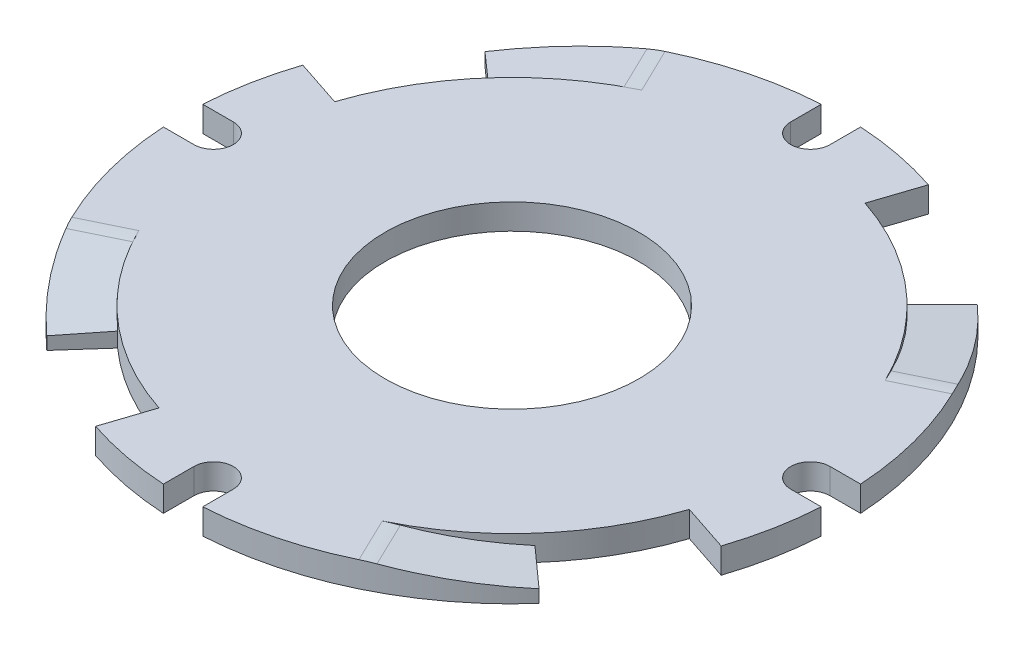
from build123d import *

# Parameters (mm, degrees)
ESQUISSE2_R                  = 10
BOSS_EXTRU_1_DEPTH           = 2
ENL_V_MAT_EXTRU_1_REACH      = 63.767
ENL_V_MAT_EXTRU_1_END_RADIUS = 22
R_P_TITION_CIRCULAIRE1_COUNT = 4


with BuildPart() as part:
    # Esquisse2 → Boss.-Extru.1 (new body)
    with BuildSketch(Plane(origin=(0, 0, 0), x_dir=(1, 0, 0), z_dir=(0, 1, 0))):
        with BuildLine():
            Line((-1.55, 25.903667694), (-1.55, 23.5))
            ThreePointArc((-1.55, 23.5), (0, 21.95), (1.55, 23.5))
            Line((1.55, 23.5), (1.55, 25.903667694))
            ThreePointArc((1.55, 25.903667694), (4.89638147, 25.483876246), (8.160057781, 24.633634669))
            Line((8.160057781, 24.633634669), (6.917968061, 20.884006271))
            ThreePointArc((6.917968061, 20.884006271), (11, 19.052558883), (14.627095933, 16.433139219))
            Line((14.627095933, 16.433139219), (17.253324521, 19.383634669))
            ThreePointArc((17.253324521, 19.383634669), (23.348257443, 11.325253832), (25.903667694, 1.55))
            Line((25.903667694, 1.55), (23.5, 1.55))
            ThreePointArc((23.5, 1.55), (21.95, 0), (23.5, -1.55))
            Line((23.5, -1.55), (25.903667694, -1.55))
            ThreePointArc((25.903667694, -1.55), (25.483876246, -4.89638147), (24.633634669, -8.160057781))
            Line((24.633634669, -8.160057781), (20.884006271, -6.917968061))
            ThreePointArc((20.884006271, -6.917968061), (19.052558883, -11), (16.433139219, -14.627095933))
            Line((16.433139219, -14.627095933), (19.383634669, -17.253324521))
            ThreePointArc((19.383634669, -17.253324521), (11.325253832, -23.348257443), (1.55, -25.903667694))
            Line((1.55, -25.903667694), (1.55, -23.5))
            ThreePointArc((1.55, -23.5), (0, -21.95), (-1.55, -23.5))
            Line((-1.55, -23.5), (-1.55, -25.903667694))
            ThreePointArc((-1.55, -25.903667694), (-4.89638147, -25.483876246), (-8.160057781, -24.633634669))
            Line((-8.160057781, -24.633634669), (-6.917968061, -20.884006271))
            ThreePointArc((-6.917968061, -20.884006271), (-11, -19.052558883), (-14.627095933, -16.433139219))
            Line((-14.627095933, -16.433139219), (-17.253324521, -19.383634669))
            ThreePointArc((-17.253324521, -19.383634669), (-23.348257443, -11.325253832), (-25.903667694, -1.55))
            Line((-25.903667694, -1.55), (-23.5, -1.55))
            ThreePointArc((-23.5, -1.55), (-21.95, 0), (-23.5, 1.55))
            Line((-23.5, 1.55), (-25.903667694, 1.55))
            ThreePointArc((-25.903667694, 1.55), (-25.483876246, 4.89638147), (-24.633634669, 8.160057781))
            Line((-24.633634669, 8.160057781), (-20.884006271, 6.917968061))
            ThreePointArc((-20.884006271, 6.917968061), (-19.052558883, 11), (-16.433139219, 14.627095933))
            Line((-16.433139219, 14.627095933), (-19.383634669, 17.253324521))
            ThreePointArc((-19.383634669, 17.253324521), (-11.325253832, 23.348257443), (-1.55, 25.903667694))
        make_face()
        with Locations(Location((0, 0, 0), (0, 0, 270))):
            Circle(ESQUISSE2_R, mode=Mode.SUBTRACT)
    extrude(amount=BOSS_EXTRU_1_DEPTH)

    # Enlèv. mat.-Extru.1: up to this cylinder (the profile starts outside it)
    enl_v_mat_extru_1_end = Plane(origin=(0, 2.23221, 0), z_dir=(0, -1, 0)) * Cylinder(ENL_V_MAT_EXTRU_1_END_RADIUS, 172.534, mode=Mode.PRIVATE)
    # Esquisse4 → Enlèv. mat.-Extru.1 (cut, up to the surface)
    with BuildSketch(Plane(origin=(23.357789239, 0, -11.305581889), x_dir=(-0.43566789553954177, 0, -0.9001074851350516), z_dir=(0.9001074851350516, 0, -0.43566789553954177)), mode=Mode.PRIVATE) as enl_v_mat_extru_1_sk1:
        with BuildLine():
            Line((9.93063507, 1), (9.93063507, 3))
            Line((9.93063507, 3), (0, 3))
            Line((0, 3), (0, 2))
            ThreePointArc((0, 2), (0.52966098, 1.985963111), (1.057835001, 1.943891849))
            Line((1.057835001, 1.943891849), (9.93063507, 1))
        make_face()
    enl_v_mat_extru_1_tool1 = extrude(enl_v_mat_extru_1_sk1.sketch, amount=-ENL_V_MAT_EXTRU_1_REACH, mode=Mode.PRIVATE) - enl_v_mat_extru_1_end
    enl_v_mat_extru_1 = enl_v_mat_extru_1_tool1.solids().sort_by_distance((20.938912, 2.23221, -16.303079))[0]
    add(enl_v_mat_extru_1, mode=Mode.SUBTRACT)

    # Répétition circulaire1: Enlèv. mat.-Extru.1 ×4 about axis
    r_p_tition_circulaire1_axis = Axis((0, 0, 0), (0, 1, 0))
    for i in range(1, R_P_TITION_CIRCULAIRE1_COUNT):
        add(enl_v_mat_extru_1.rotate(r_p_tition_circulaire1_axis, i * 360 / R_P_TITION_CIRCULAIRE1_COUNT), mode=Mode.SUBTRACT)


solid = part.part
